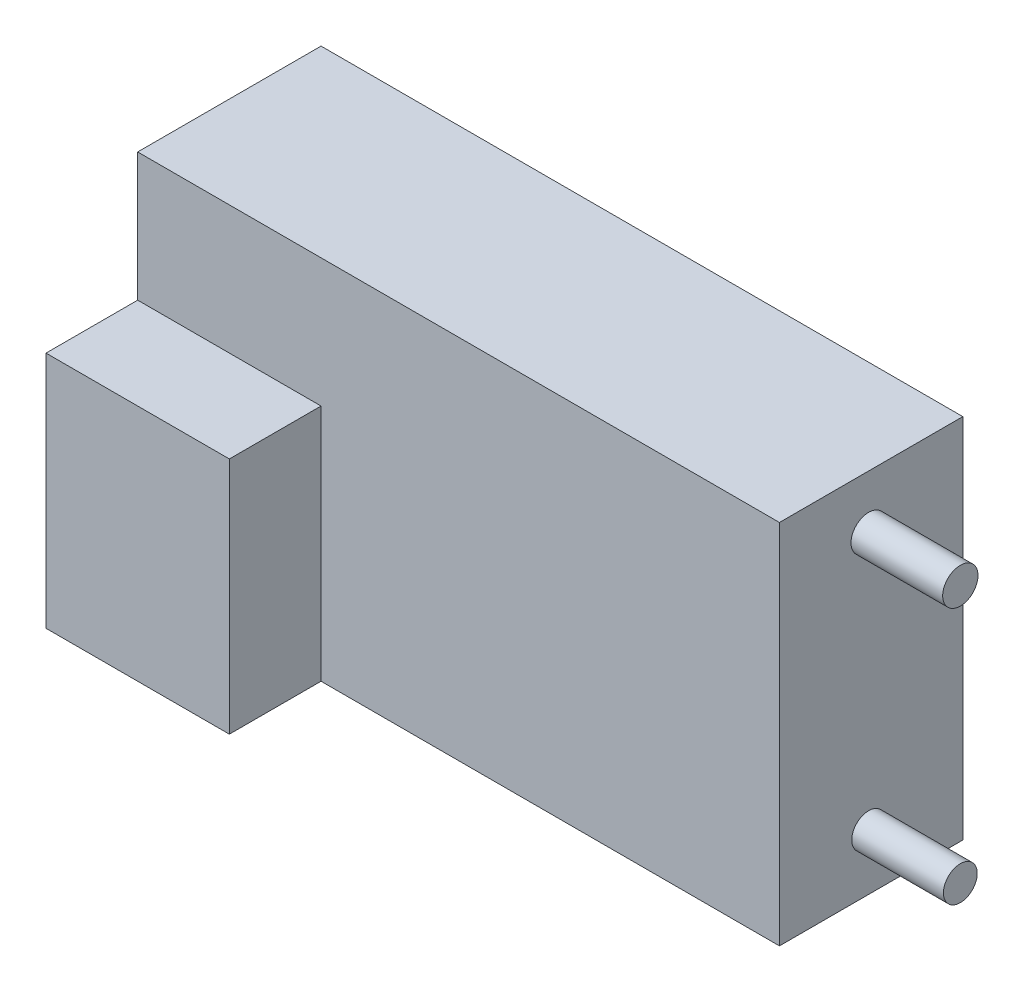
from build123d import *

# Parameters (mm, degrees)
ESBO_O1_W                = 35
ESBO_O1_H                = 20
RESSALTO_EXTRUS_O1_DEPTH = 10
ESBO_O2_W                = 10
ESBO_O2_H                = 13
RESSALTO_EXTRUS_O2_DEPTH = 5
ESBO_O3_R                = 0.922121428
ESBO_O3_R_2              = 0.963466347
RESSALTO_EXTRUS_O3_DEPTH = 5


with BuildPart() as part:
    # Esboço1 → Ressalto-extrusão1 (new body)
    with BuildSketch(Plane.XY):
        with Locations((1.225709868, 0.66677589)):
            Rectangle(ESBO_O1_W, ESBO_O1_H)
    extrude(amount=RESSALTO_EXTRUS_O1_DEPTH)

    # Esboço2 → Ressalto-extrusão2 (add)
    with BuildSketch(Plane.XY.offset(10)):
        with Locations((-11.274290132, -2.83322411)):
            Rectangle(ESBO_O2_W, ESBO_O2_H)
    extrude(amount=RESSALTO_EXTRUS_O2_DEPTH)

    # Esboço3 → Ressalto-extrusão3 (add)
    with BuildSketch(Plane(origin=(18.725709868, 0, 0), x_dir=(0, 0, -1), z_dir=(1, 0, 0))):
        with Locations((-5.13508621, -6.301169804)):
            Circle(ESBO_O3_R)
        with Locations((-5.13508621, 7.750286856)):
            Circle(ESBO_O3_R_2)
    extrude(amount=RESSALTO_EXTRUS_O3_DEPTH)


solid = part.part
